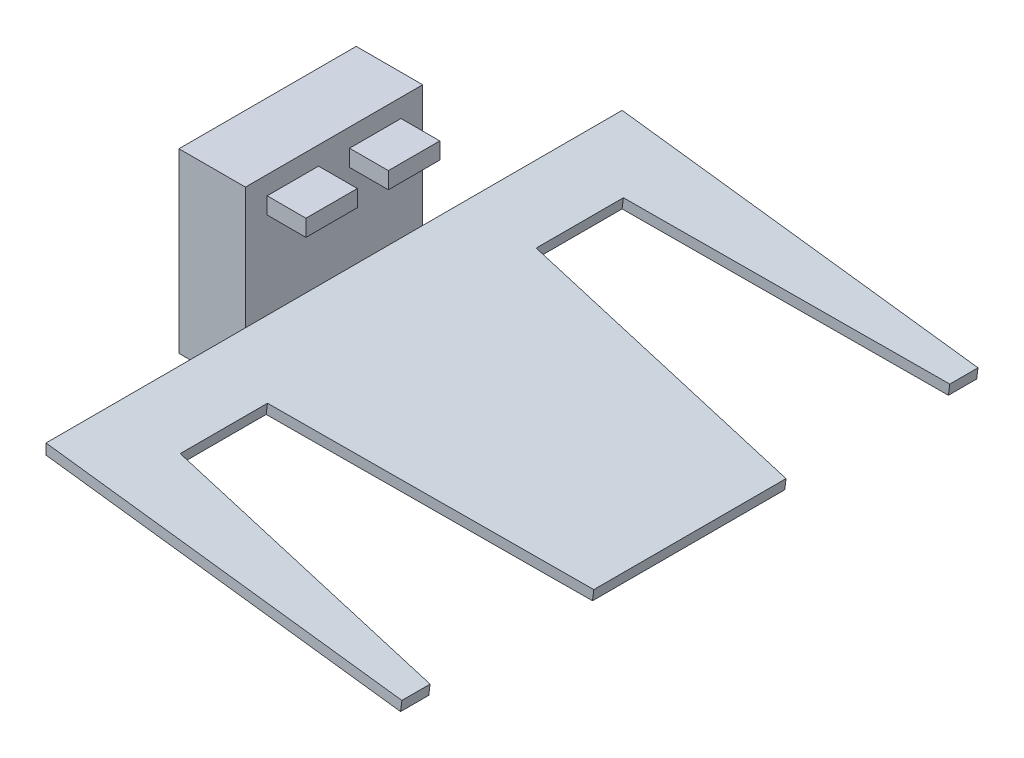
from build123d import *

# Parameters (mm, degrees)
SKETCH1_W        = 19.05
SKETCH1_H        = 50.8
EXTRUDE1_DEPTH   = 25.4
SHELL1_T         = -1.5875
EXTRUDE3_DEPTH   = 82.55
EXTRUDE4_DEPTH   = 25
SKETCH5_W        = 14.732
SKETCH5_H        = 4.7625
EXTRUDE5_DEPTH   = 11.1125
EXTRUDE5_2_DEPTH = 11.1125
EXTRUDE10_DEPTH  = 2.9972


with BuildPart() as part:
    # Sketch1 → Extrude1 (new body, symmetric)
    with BuildSketch(Plane.XY):
        with Locations((0, 25.4)):
            Rectangle(SKETCH1_W, SKETCH1_H)
    extrude(amount=EXTRUDE1_DEPTH, both=True)

    # Shell1
    shell1_openings = [part.faces().sort_by_distance(p)[0] for p in [
        (0, 0, 0),
    ]]
    offset(amount=SHELL1_T, openings=shell1_openings, kind=Kind.INTERSECTION)


with BuildPart() as body_2:
    # Sketch3 → Extrude3 (new body, symmetric)
    with BuildSketch(Plane.XY):
        Polygon((9.525, 15.875), (111.501191593, 2.973497558), (111.125, 0), (9.525, 12.85390862), align=None)
    extrude(amount=EXTRUDE3_DEPTH, both=True)

    # Sketch4 → Extrude4 (cut)
    with BuildSketch(Plane.XY.offset(63.5)):
        with BuildLine():
            Line((63.337117092, 9.066968152), (28.938004512, 13.418966673))
            ThreePointArc((28.938004512, 13.418966673), (44.989198765, 2.166072097), (63.337117092, 9.066968152))
        make_face()
    extrude4 = extrude(amount=-EXTRUDE4_DEPTH, mode=Mode.SUBTRACT)

    # Mirror1: Extrude4 across plane
    add(extrude4.mirror(Plane.XY), mode=Mode.SUBTRACT)

    # Sketch9 → Extrude10 (cut)
    with BuildSketch(Plane(origin=(2.12683825, 16.810977314, 0), x_dir=(0.992091805, -0.125514345, 0), z_dir=(0.125514345, 0.992091805, 0))):
        Polygon((27.02488432, 38.5), (110.246201818, 27.543705699), (110.246201818, 74.456294301), (27.02488432, 63.5), align=None)
        Polygon((27.02488432, -63.5), (110.246201818, -74.456294301), (110.246201818, -27.543705699), (27.02488432, -38.5), align=None)
    extrude(amount=-EXTRUDE10_DEPTH, mode=Mode.SUBTRACT)


with BuildPart() as body_3:
    # Sketch5 → Extrude5 (new body)
    with BuildSketch(Plane(origin=(9.525, 0, 0), x_dir=(0, 0, -1), z_dir=(1, 0, 0))):
        with Locations((-11.811, 43.146500004)):
            Rectangle(SKETCH5_W, SKETCH5_H)
    extrude(amount=EXTRUDE5_DEPTH)


with BuildPart() as body_4:
    # Sketch5 → Extrude5 2 (new body)
    with BuildSketch(Plane(origin=(9.525, 0, 0), x_dir=(0, 0, -1), z_dir=(1, 0, 0))):
        with Locations((11.811, 43.146500004)):
            Rectangle(SKETCH5_W, SKETCH5_H)
    extrude(amount=EXTRUDE5_2_DEPTH)


solid = Compound([part.part, body_2.part, body_3.part, body_4.part])
